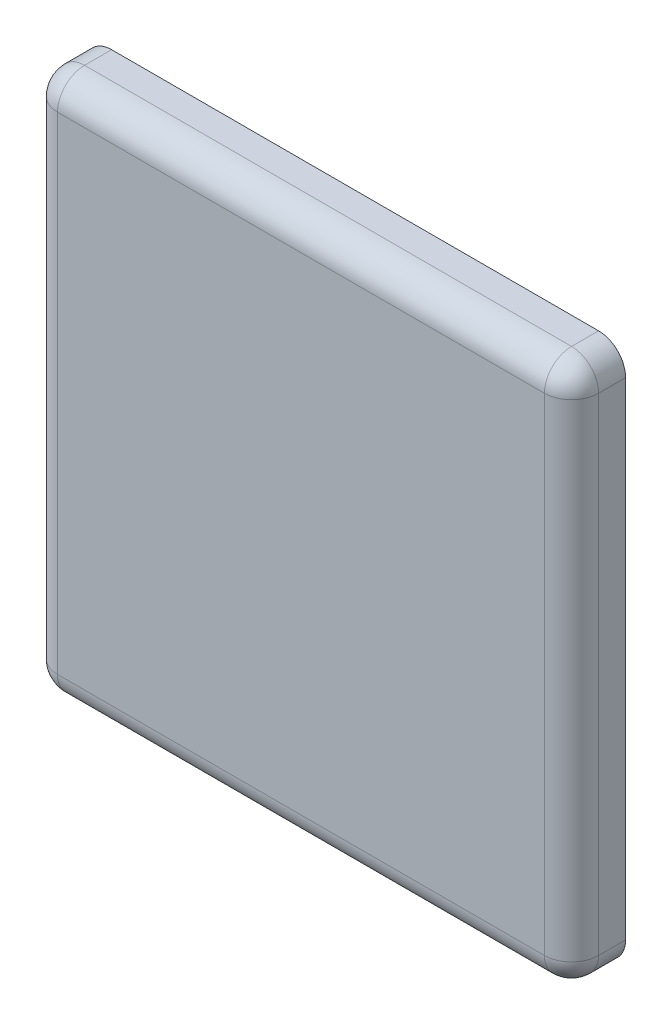
from build123d import *

# Parameters (mm, degrees)
SKETCH1_W      = 20
SKETCH1_H      = 20
EXTRUDE1_DEPTH = 2
FILLET1_R      = 1


with BuildPart() as part:
    # Sketch1 → Extrude1 (new body)
    with BuildSketch(Plane.XY):
        with Locations((10, 10)):
            Rectangle(SKETCH1_W, SKETCH1_H)
    extrude(amount=EXTRUDE1_DEPTH)

    # Fillet1
    fillet1_edges = [part.edges().sort_by_distance(p)[0] for p in [
        (20, 10, 2),
        (10, 20, 2),
        (0, 10, 2),
        (10, 0, 2),
        (0, 20, 1),
        (20, 20, 1),
        (20, 0, 1),
        (0, 0, 1),
    ]]
    fillet(fillet1_edges, radius=FILLET1_R)


solid = part.part
